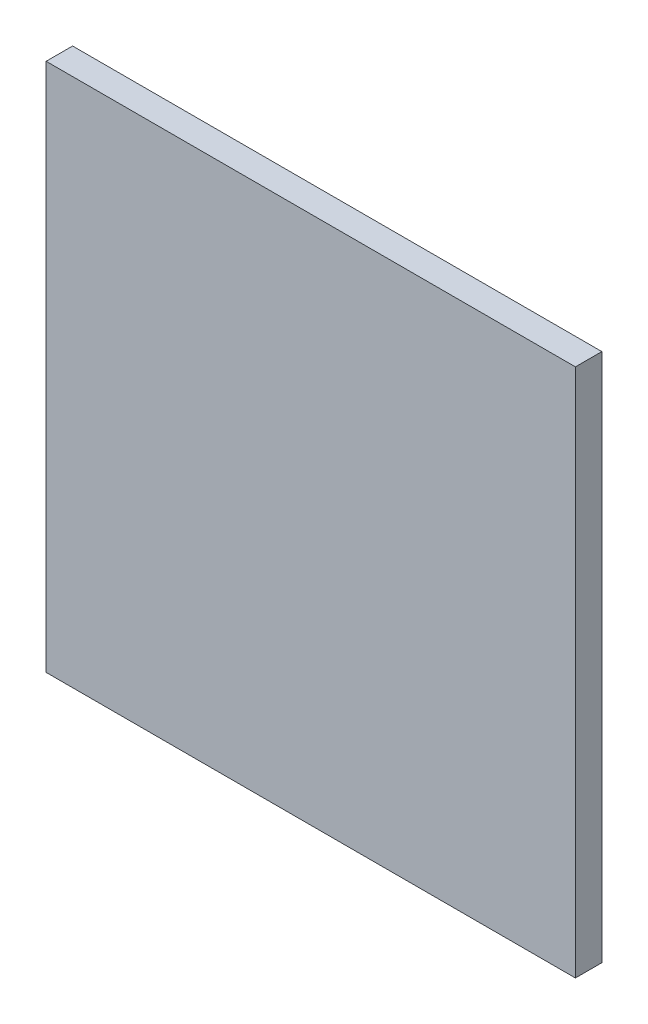
from build123d import *

# Parameters (mm, degrees)
SCHIZZO1_W                   = 20
SCHIZZO1_H                   = 20
ESTRUSIONE_ESTRUSIONE1_DEPTH = 1


with BuildPart() as part:
    # Schizzo1 → Estrusione-Estrusione1 (new body)
    with BuildSketch(Plane.XY):
        Rectangle(SCHIZZO1_W, SCHIZZO1_H)
    extrude(amount=ESTRUSIONE_ESTRUSIONE1_DEPTH)


solid = part.part
